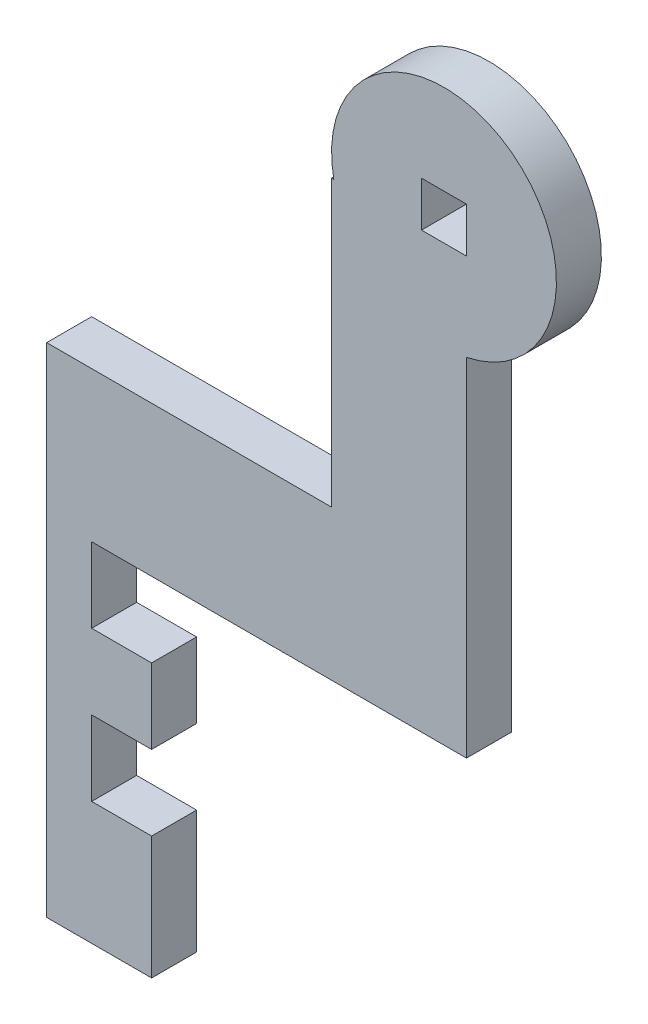
from build123d import *

# Parameters (mm, degrees)
SKETCH2_W           = 28
SKETCH2_H           = 33.2
BOSS_EXTRUDE1_DEPTH = 3
SKETCH4_W           = 21
SKETCH4_H           = 5
SKETCH4_H_2         = 8.2
CUT_EXTRUDE1_DEPTH  = 3
BOSS_EXTRUDE2_DEPTH = 3


with BuildPart() as part:
    # Sketch2 → Boss-Extrude1 (new body)
    with BuildSketch(Plane.XY):
        Rectangle(SKETCH2_W, SKETCH2_H)
    extrude(amount=BOSS_EXTRUDE1_DEPTH)

    # Sketch4 → Cut-Extrude1 (cut)
    with BuildSketch(Plane.XY.offset(3)):
        Polygon((14, 1.6), (14, 6.6), (-11, 6.6), (-11, 1.6), (-7, 1.6), align=None)
        with Locations((3.5, -0.9)):
            Rectangle(SKETCH4_W, SKETCH4_H)
        Polygon((14, -8.4), (14, -3.4), (-7, -3.4), (-11, -3.4), (-11, -8.4), (-7, -8.4), align=None)
        with Locations((3.5, -12.5)):
            Rectangle(SKETCH4_W, SKETCH4_H_2)
    extrude(amount=-CUT_EXTRUDE1_DEPTH, mode=Mode.SUBTRACT)

    # Sketch5 → Boss-Extrude2 (add)
    with BuildSketch(Plane.XY.offset(3)):
        with BuildLine():
            Line((11, 29.751530772), (11, 35.6))
            Line((11, 35.6), (5.151530772, 35.6))
            ThreePointArc((5.151530772, 35.6), (7.196699141, 31.796699141), (11, 29.751530772))
        make_face()
        with BuildLine():
            Line((11, 16.6), (11, 29.751530772))
            ThreePointArc((11, 29.751530772), (7.196699141, 31.796699141), (5.151530772, 35.6))
            Line((5.151530772, 35.6), (5, 35.6))
            Line((5, 35.6), (5, 16.6))
            Line((5, 16.6), (11, 16.6))
        make_face()
        with BuildLine():
            Line((14, 16.6), (14, 29.751530772))
            ThreePointArc((14, 29.751530772), (12.5, 29.6), (11, 29.751530772))
            Line((11, 29.751530772), (11, 16.6))
            Line((11, 16.6), (14, 16.6))
        make_face()
        with BuildLine():
            Line((14, 29.751530772), (14, 35.6))
            Line((14, 35.6), (11, 35.6))
            Line((11, 35.6), (11, 29.751530772))
            ThreePointArc((11, 29.751530772), (12.5, 29.6), (14, 29.751530772))
        make_face()
        with BuildLine():
            Line((14, 38.6), (14, 35.6))
            Line((14, 35.6), (14, 29.751530772))
            ThreePointArc((14, 29.751530772), (18.309475019, 32.35658351), (20, 37.1))
            ThreePointArc((20, 37.1), (11.746182785, 44.562021148), (5.151530772, 35.6))
            Line((5.151530772, 35.6), (11, 35.6))
            Line((11, 35.6), (11, 38.6))
            Line((11, 38.6), (14, 38.6))
        make_face()
    extrude(amount=-BOSS_EXTRUDE2_DEPTH)


solid = part.part
